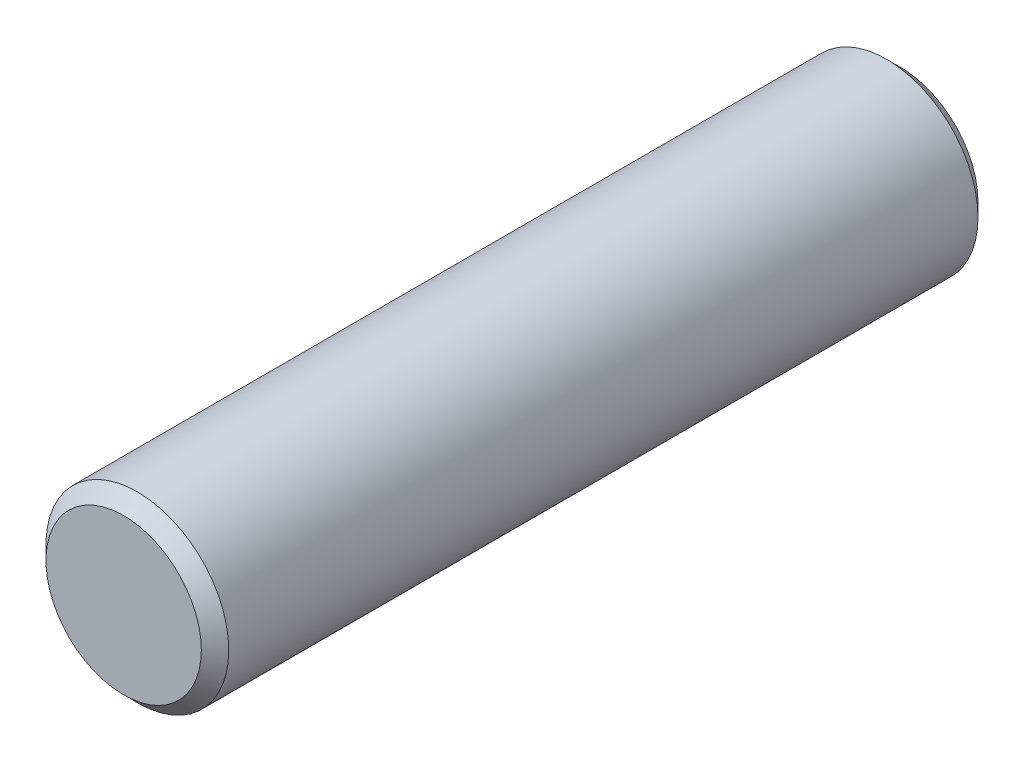
from build123d import *

# Parameters (mm, degrees)
SKETCH1_R           = 2
BOSS_EXTRUDE1_DEPTH = 17
CHAMFER1_SIZE       = 0.3


with BuildPart() as part:
    # Sketch1 → Boss-Extrude1 (new body)
    with BuildSketch(Plane.XY):
        Circle(SKETCH1_R)
    extrude(amount=BOSS_EXTRUDE1_DEPTH)

    # Chamfer1
    chamfer1_edges = [part.edges().sort_by_distance(p)[0] for p in [
        (-2, 0, 0),
        (-2, 0, 17),
    ]]
    chamfer(chamfer1_edges, length=CHAMFER1_SIZE)


solid = part.part
